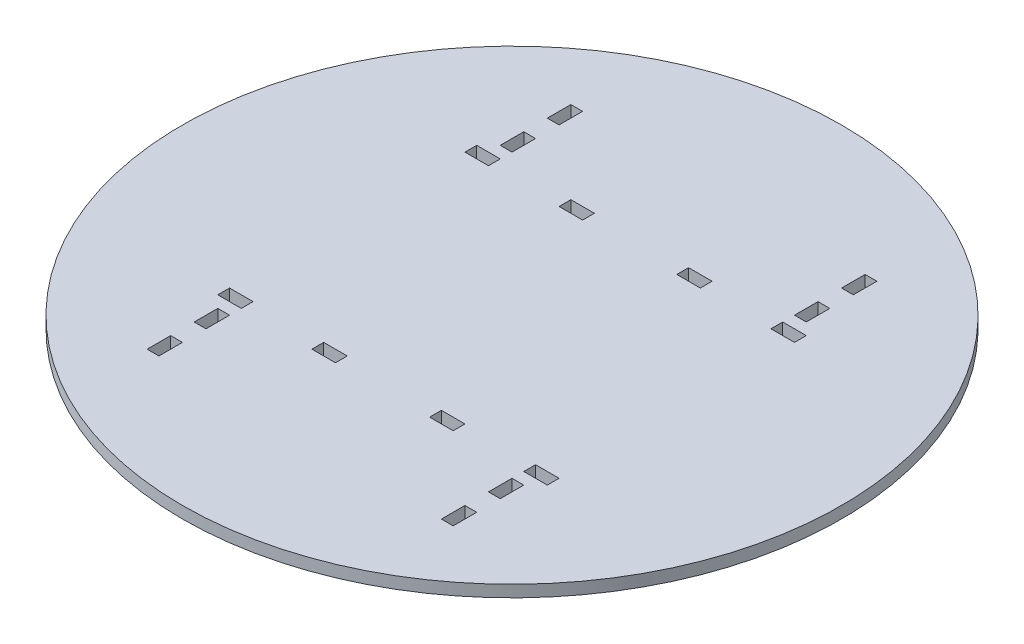
from build123d import *

# Parameters (mm, degrees)
SKETCH1_W           = 6.35
SKETCH1_H           = 12.7
SKETCH1_W_2         = 12.7
SKETCH1_H_2         = 6.35
BOSS_EXTRUDE1_DEPTH = 6.35


with BuildPart() as part:
    # Sketch1 → Boss-Extrude1 (new body)
    with BuildSketch(Plane(origin=(0, 0, 0), x_dir=(1, 0, 0), z_dir=(0, 1, 0))):
        with BuildLine():
            Line((0, -177.8), (0, 0))
            Line((0, 0), (-177.8, 0))
            ThreePointArc((-177.8, 0), (-125.723585695, -125.723585695), (0, -177.8))
        make_face()
        with Locations((-79.375, -107.95)):
            Rectangle(SKETCH1_W, SKETCH1_H, mode=Mode.SUBTRACT)
        with Locations((-79.375, -82.55)):
            Rectangle(SKETCH1_W, SKETCH1_H, mode=Mode.SUBTRACT)
        with Locations((-82.55, -66.675)):
            Rectangle(SKETCH1_W_2, SKETCH1_H_2, mode=Mode.SUBTRACT)
        with Locations((-31.75, -66.675)):
            Rectangle(SKETCH1_W_2, SKETCH1_H_2, mode=Mode.SUBTRACT)
        with BuildLine():
            Line((177.8, 0), (0, 0))
            Line((0, 0), (0, -177.8))
            ThreePointArc((0, -177.8), (125.723585695, -125.723585695), (177.8, 0))
        make_face()
        with Locations((79.375, -107.95)):
            Rectangle(SKETCH1_W, SKETCH1_H, mode=Mode.SUBTRACT)
        with Locations((31.75, -66.675)):
            Rectangle(SKETCH1_W_2, SKETCH1_H_2, mode=Mode.SUBTRACT)
        with Locations((79.375, -82.55)):
            Rectangle(SKETCH1_W, SKETCH1_H, mode=Mode.SUBTRACT)
        with Locations((82.55, -66.675)):
            Rectangle(SKETCH1_W_2, SKETCH1_H_2, mode=Mode.SUBTRACT)
        with BuildLine():
            ThreePointArc((177.8, 0), (125.723585695, 125.723585695), (0, 177.8))
            Line((0, 177.8), (0, 0))
            Line((0, 0), (177.8, 0))
        make_face()
        with Locations((31.75, 66.675)):
            Rectangle(SKETCH1_W_2, SKETCH1_H_2, mode=Mode.SUBTRACT)
        with Locations((82.55, 66.675)):
            Rectangle(SKETCH1_W_2, SKETCH1_H_2, mode=Mode.SUBTRACT)
        with Locations((79.375, 82.55)):
            Rectangle(SKETCH1_W, SKETCH1_H, mode=Mode.SUBTRACT)
        with Locations((79.375, 107.95)):
            Rectangle(SKETCH1_W, SKETCH1_H, mode=Mode.SUBTRACT)
        with BuildLine():
            Line((0, 0), (0, 177.8))
            ThreePointArc((0, 177.8), (-125.723585695, 125.723585695), (-177.8, 0))
            Line((-177.8, 0), (0, 0))
        make_face()
        with Locations((-82.55, 66.675)):
            Rectangle(SKETCH1_W_2, SKETCH1_H_2, mode=Mode.SUBTRACT)
        with Locations((-79.375, 82.55)):
            Rectangle(SKETCH1_W, SKETCH1_H, mode=Mode.SUBTRACT)
        with Locations((-31.75, 66.675)):
            Rectangle(SKETCH1_W_2, SKETCH1_H_2, mode=Mode.SUBTRACT)
        with Locations((-79.375, 107.95)):
            Rectangle(SKETCH1_W, SKETCH1_H, mode=Mode.SUBTRACT)
    extrude(amount=BOSS_EXTRUDE1_DEPTH)


solid = part.part
